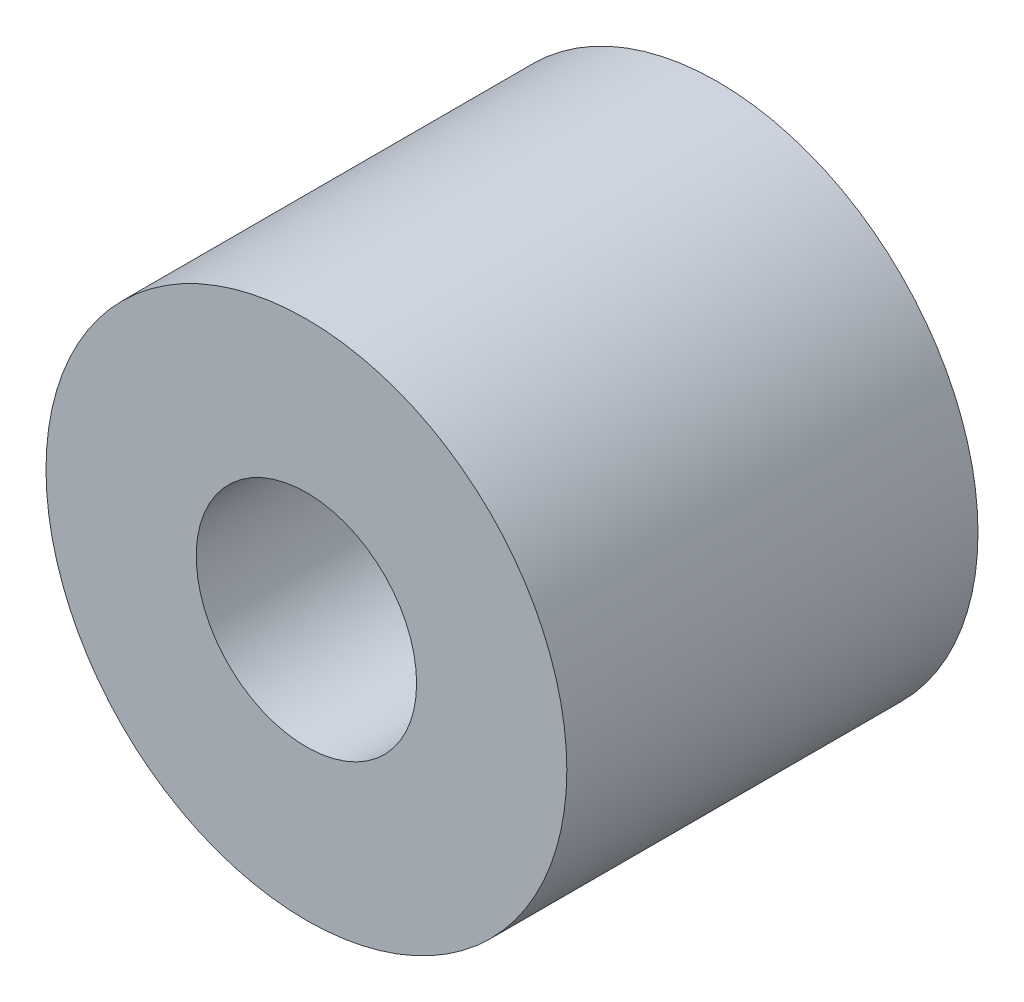
from build123d import *

# Parameters (mm, degrees)
SKETCH1_R                   = 6.0325
BOSS_EXTRUDE1_DEPTH         = 4.7625
TAP_DRILL_FOR_1_4_20_TAP1_D = 5.1054


with BuildPart() as part:
    # Sketch1 → Boss-Extrude1 (new body, symmetric)
    with BuildSketch(Plane.XY):
        Circle(SKETCH1_R)
    extrude(amount=BOSS_EXTRUDE1_DEPTH, both=True)

    # Tap Drill for 1/4-20 Tap1 (through all)
    with Locations(Plane.XY.offset(4.7625)):
        with Locations((0, 0)):
            Hole(TAP_DRILL_FOR_1_4_20_TAP1_D / 2)


solid = part.part
